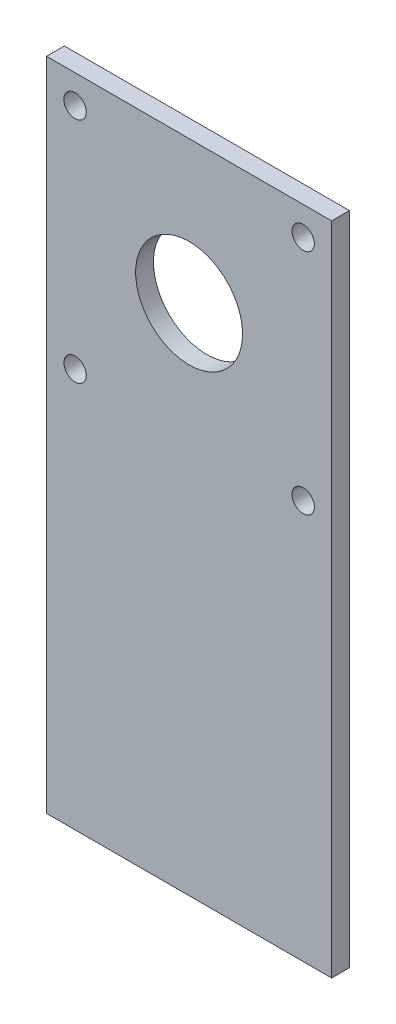
from build123d import *

# Parameters (mm, degrees)
SKETCH2_W           = 50.8
SKETCH2_H           = 50.8
SKETCH2_R           = 2
SKETCH2_R_2         = 9.525
BOSS_EXTRUDE1_DEPTH = 3.175
SKETCH3_W           = 50.8
SKETCH3_H           = 3.175
BOSS_EXTRUDE2_DEPTH = 66.04


with BuildPart() as part:
    # Sketch2 → Boss-Extrude1 (new body)
    with BuildSketch(Plane.XY):
        with Locations((25.4, 25.4)):
            Rectangle(SKETCH2_W, SKETCH2_H)
        with Locations((5.08, 45.72)):
            Circle(SKETCH2_R, mode=Mode.SUBTRACT)
        with Locations((45.72, 45.72)):
            Circle(SKETCH2_R, mode=Mode.SUBTRACT)
        with Locations((45.72, 5.08)):
            Circle(SKETCH2_R, mode=Mode.SUBTRACT)
        with Locations((5.08, 5.08)):
            Circle(SKETCH2_R, mode=Mode.SUBTRACT)
        with Locations((25.4, 25.4)):
            Circle(SKETCH2_R_2, mode=Mode.SUBTRACT)
    extrude(amount=BOSS_EXTRUDE1_DEPTH)

    # Sketch3 → Boss-Extrude2 (add)
    with BuildSketch(Plane.XZ):
        with Locations((25.4, 1.5875)):
            Rectangle(SKETCH3_W, SKETCH3_H)
    extrude(amount=BOSS_EXTRUDE2_DEPTH)


solid = part.part
